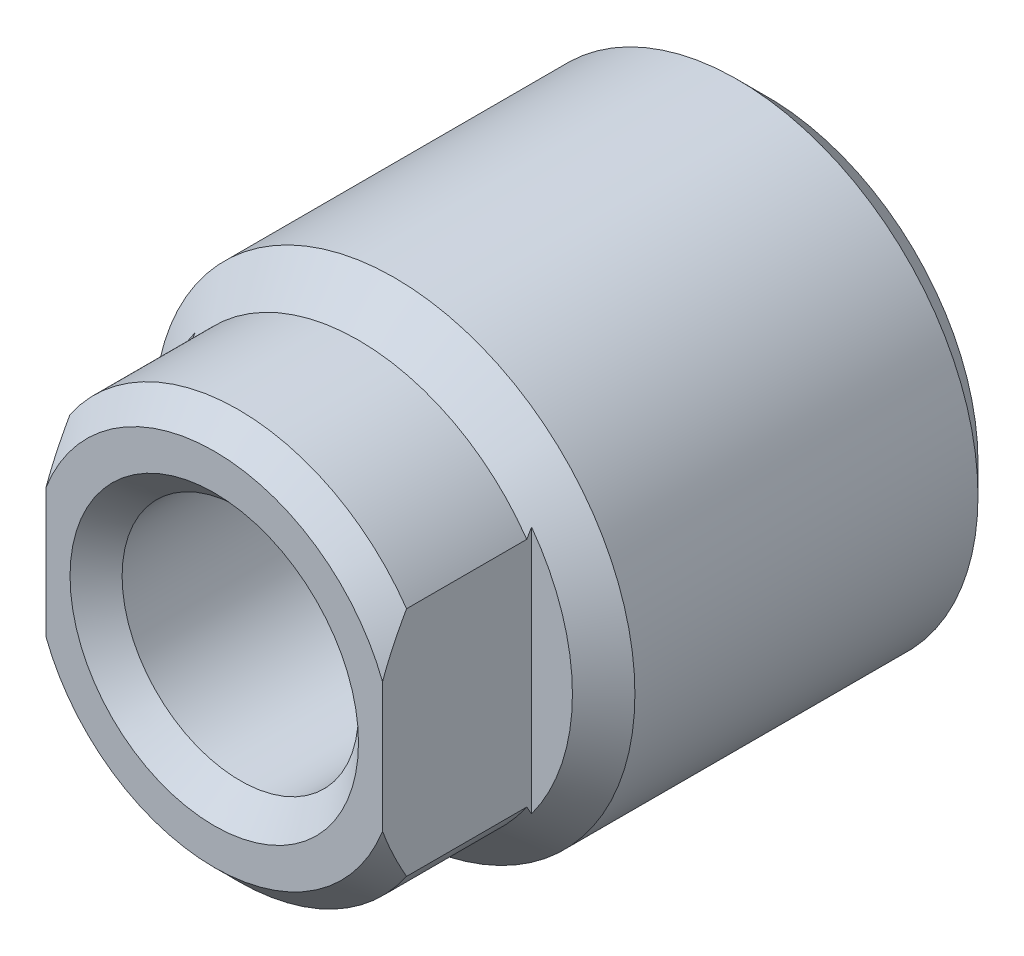
from build123d import *

# Parameters (mm, degrees)
SCHNITT_LINEAR_AUSTRAGEN1_DEPTH      = 30
SCHNITT_LINEAR_AUSTRAGEN1_DEPTH_BACK = 30


with BuildPart() as part:
    # Skizze1 → Rotation1 (revolve)
    with BuildSketch(Plane(origin=(0, 0, 0), x_dir=(0, 0, -1), z_dir=(1, 0, 0))):
        Polygon((-11.5, 3.75), (-11.5, 3), (-10.9585, 2.4585), (-0.5415, 2.4585), (0, 3), (0, 4.3865), (-0.6135, 5), (-7.75, 5), (-8.5, 4.25), (-11, 4.25), align=None)
    revolve(axis=Axis((0, 0, 0), (0, 0, 1)))

    # Skizze2 → Schnitt-Linear austragen1 (cut, two sides: drawn at the far end of the back side and taken through both)
    with BuildSketch(Plane(origin=(0, 0, 0), x_dir=(1, 0, 0), z_dir=(0, 1, 0)).offset(-SCHNITT_LINEAR_AUSTRAGEN1_DEPTH_BACK)):
        Polygon((-13.5, -23.4), (13.5, -23.4), (13.5, -8.4), (3.5, -8.4), (3.5, -18.4), (-3.5, -18.4), (-3.5, -8.4), (-13.5, -8.4), align=None)
    extrude(amount=SCHNITT_LINEAR_AUSTRAGEN1_DEPTH + SCHNITT_LINEAR_AUSTRAGEN1_DEPTH_BACK, mode=Mode.SUBTRACT)


solid = part.part
